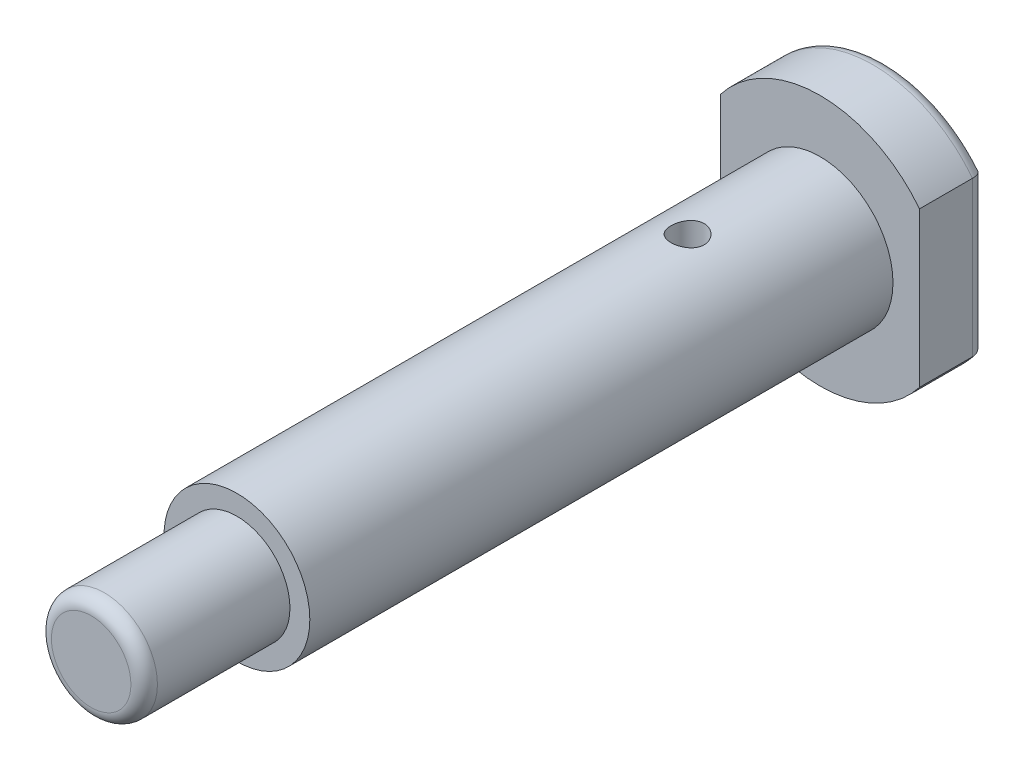
from build123d import *

# Parameters (mm, degrees)
SKETCH1_R           = 8
BOSS_EXTRUDE1_DEPTH = 120
SKETCH1_3_R         = 11
SKETCH1_3_R_2       = 8
BOSS_EXTRUDE2_DEPTH = 98
SKETCH1_4_R         = 11
BOSS_EXTRUDE3_DEPTH = 10
BOSS_EXTRUDE4_DEPTH = 10
FILLET5_R           = 2
FILLET6_R           = 2
CUT_EXTRUDE1_DEPTH  = 100


with BuildPart() as part:
    # Sketch1 → Boss-Extrude1 (new body)
    with BuildSketch(Plane.XY):
        with Locations((-32.852244642, 0)):
            Circle(SKETCH1_R)
    extrude(amount=BOSS_EXTRUDE1_DEPTH)

    # Sketch1_3 → Boss-Extrude2 (add)
    with BuildSketch(Plane.XY):
        with Locations((-32.852244642, 0)):
            Circle(SKETCH1_3_R)
        with Locations((-32.852244642, 0)):
            Circle(SKETCH1_3_R_2, mode=Mode.SUBTRACT)
    extrude(amount=BOSS_EXTRUDE2_DEPTH)

    # Sketch1_4 → Boss-Extrude3 (add)
    with BuildSketch(Plane.XY):
        with BuildLine():
            Line((-17.852244642, -9.949874371), (-17.852244642, 9.949874371))
            ThreePointArc((-17.852244642, 9.949874371), (-32.852244642, 18), (-47.852244642, 9.949874371))
            Line((-47.852244642, 9.949874371), (-47.852244642, -9.949874371))
            ThreePointArc((-47.852244642, -9.949874371), (-32.852244642, -18), (-17.852244642, -9.949874371))
        make_face()
        with Locations((-32.852244642, 0)):
            Circle(SKETCH1_4_R, mode=Mode.SUBTRACT)
    extrude(amount=BOSS_EXTRUDE3_DEPTH)

    # Sketch1_6 → Boss-Extrude4 (add)
    with BuildSketch(Plane.XY):
        with BuildLine():
            Line((-47.852244642, 11.66190379), (-47.852244642, 9.949874371))
            ThreePointArc((-47.852244642, 9.949874371), (-32.852244642, 18), (-17.852244642, 9.949874371))
            Line((-17.852244642, 9.949874371), (-17.852244642, 11.66190379))
            ThreePointArc((-17.852244642, 11.66190379), (-32.852244642, 19), (-47.852244642, 11.66190379))
        make_face()
        with BuildLine():
            ThreePointArc((-17.852244642, -9.949874371), (-32.852244642, -18), (-47.852244642, -9.949874371))
            Line((-47.852244642, -9.949874371), (-47.852244642, -11.66190379))
            ThreePointArc((-47.852244642, -11.66190379), (-32.852244642, -19), (-17.852244642, -11.66190379))
            Line((-17.852244642, -11.66190379), (-17.852244642, -9.949874371))
        make_face()
    extrude(amount=BOSS_EXTRUDE4_DEPTH)

    # Fillet5
    fillet5_edges = [part.edges().sort_by_distance(p)[0] for p in [
        (-32.852244642, -19, 0),
        (-17.852244642, 0, 0),
        (-32.852244642, 19, 0),
        (-47.852244642, 0, 0),
    ]]
    fillet(fillet5_edges, radius=FILLET5_R)

    # Fillet6
    fillet6_edges = [part.edges().sort_by_distance(p)[0] for p in [
        (-40.852244642, 0, 120),
    ]]
    fillet(fillet6_edges, radius=FILLET6_R)

    # Sketch2 → Cut-Extrude1 (cut)
    with BuildSketch(Plane(origin=(0, 11, 0), x_dir=(1, 0, 0), z_dir=(0, 1, 0))):
        with BuildLine():
            ThreePointArc((-32.852244642, -27.5), (-34.620011595, -31.767766953), (-30.352244642, -30))
            ThreePointArc((-30.352244642, -30), (-31.084477689, -28.232233047), (-32.852244642, -27.5))
        make_face()
    extrude(amount=-CUT_EXTRUDE1_DEPTH, mode=Mode.SUBTRACT)


solid = part.part
